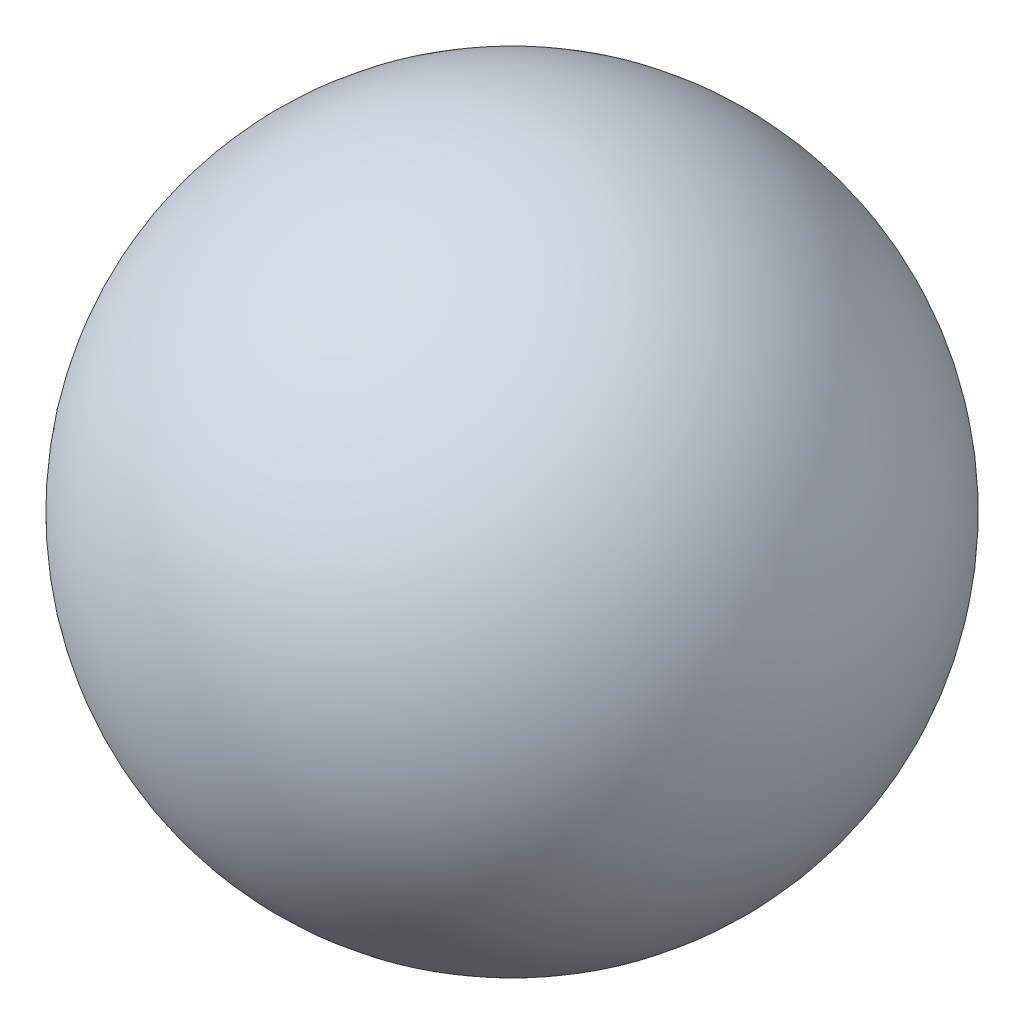
from build123d import *


with BuildPart() as part:
    # Sketch1 → Revolve1 (revolve)
    with BuildSketch(Plane.XY):
        with BuildLine():
            Line((0, 254), (0, 0))
            ThreePointArc((0, 0), (127, 127), (0, 254))
        make_face()
    revolve(axis=Axis((0, 254, 0), (0, -1, 0)))


solid = part.part
